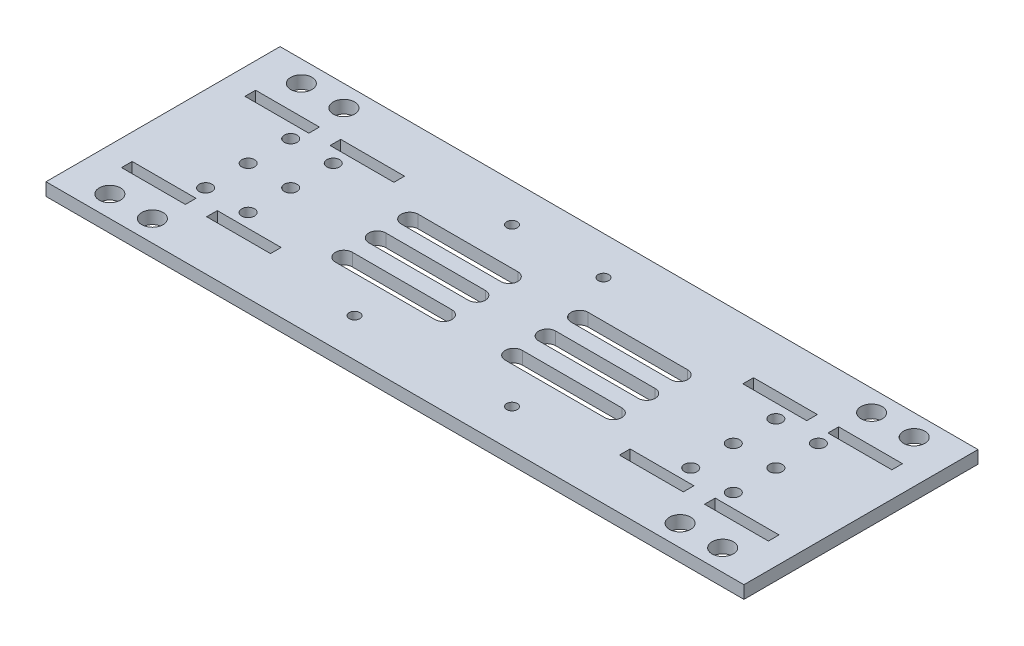
from build123d import *

# Parameters (mm, degrees)
SKETCH1_W           = 164
SKETCH1_H           = 55
SKETCH1_W_2         = 15
SKETCH1_H_2         = 2.5
BOSS_EXTRUDE1_DEPTH = 3
CUT_EXTRUDE1_DEPTH  = 3
SKETCH3_R           = 1.25
CUT_EXTRUDE2_DEPTH  = 10
SKETCH4_R           = 2.5
CUT_EXTRUDE3_DEPTH  = 4
SKETCH5_R           = 1.5
CUT_EXTRUDE4_DEPTH  = 10


with BuildPart() as part:
    # Sketch1 → Boss-Extrude1 (new body)
    with BuildSketch(Plane(origin=(0, 0, 0), x_dir=(1, 0, 0), z_dir=(0, 1, 0))):
        Rectangle(SKETCH1_W, SKETCH1_H)
        with Locations((48.5, 14.5)):
            Rectangle(SKETCH1_W_2, SKETCH1_H_2, mode=Mode.SUBTRACT)
        with Locations((68.5, 14.5)):
            Rectangle(SKETCH1_W_2, SKETCH1_H_2, mode=Mode.SUBTRACT)
        with Locations((68.5, -14.5)):
            Rectangle(SKETCH1_W_2, SKETCH1_H_2, mode=Mode.SUBTRACT)
        with Locations((48.5, -14.5)):
            Rectangle(SKETCH1_W_2, SKETCH1_H_2, mode=Mode.SUBTRACT)
        with Locations((-48.5, -14.5)):
            Rectangle(SKETCH1_W_2, SKETCH1_H_2, mode=Mode.SUBTRACT)
        with Locations((-68.5, -14.5)):
            Rectangle(SKETCH1_W_2, SKETCH1_H_2, mode=Mode.SUBTRACT)
        with Locations((-68.5, 14.5)):
            Rectangle(SKETCH1_W_2, SKETCH1_H_2, mode=Mode.SUBTRACT)
        with Locations((-48.5, 14.5)):
            Rectangle(SKETCH1_W_2, SKETCH1_H_2, mode=Mode.SUBTRACT)
    extrude(amount=BOSS_EXTRUDE1_DEPTH)

    # Sketch2 → Cut-Extrude1 (cut)
    with BuildSketch(Plane(origin=(0, 3, 0), x_dir=(1, 0, 0), z_dir=(0, 1, 0))):
        with BuildLine():
            Line((-31.658505885, 2), (-8.266387648, 2))
            ThreePointArc((-8.266387648, 2), (-6.266387648, 0), (-8.266387648, -2))
            Line((-8.266387648, -2), (-31.658505885, -2))
            ThreePointArc((-31.658505885, -2), (-33.658505885, 0), (-31.658505885, 2))
        make_face()
        with BuildLine():
            Line((31.658505885, -9.856733432), (8.266387648, -9.856733432))
            ThreePointArc((8.266387648, -9.856733432), (6.266387648, -7.856733432), (8.266387648, -5.856733432))
            Line((8.266387648, -5.856733432), (31.658505885, -5.856733432))
            ThreePointArc((31.658505885, -5.856733432), (33.658505885, -7.856733432), (31.658505885, -9.856733432))
        make_face()
        with BuildLine():
            Line((-31.658505885, 9.620758334), (-8.266387648, 9.620758334))
            ThreePointArc((-8.266387648, 9.620758334), (-6.266387648, 7.620758334), (-8.266387648, 5.620758334))
            Line((-8.266387648, 5.620758334), (-31.658505885, 5.620758334))
            ThreePointArc((-31.658505885, 5.620758334), (-33.658505885, 7.620758334), (-31.658505885, 9.620758334))
        make_face()
        with BuildLine():
            Line((31.658505885, 5.620758334), (8.266387648, 5.620758334))
            ThreePointArc((8.266387648, 5.620758334), (6.266387648, 7.620758334), (8.266387648, 9.620758334))
            Line((8.266387648, 9.620758334), (31.658505885, 9.620758334))
            ThreePointArc((31.658505885, 9.620758334), (33.658505885, 7.620758334), (31.658505885, 5.620758334))
        make_face()
        with BuildLine():
            Line((-31.658505885, -5.856733432), (-8.266387648, -5.856733432))
            ThreePointArc((-8.266387648, -5.856733432), (-6.266387648, -7.856733432), (-8.266387648, -9.856733432))
            Line((-8.266387648, -9.856733432), (-31.658505885, -9.856733432))
            ThreePointArc((-31.658505885, -9.856733432), (-33.658505885, -7.856733432), (-31.658505885, -5.856733432))
        make_face()
        with BuildLine():
            Line((31.658505885, -2), (8.266387648, -2))
            ThreePointArc((8.266387648, -2), (6.266387648, 0), (8.266387648, 2))
            Line((8.266387648, 2), (31.658505885, 2))
            ThreePointArc((31.658505885, 2), (33.658505885, 0), (31.658505885, -2))
        make_face()
    extrude(amount=-CUT_EXTRUDE1_DEPTH, mode=Mode.SUBTRACT)

    # Sketch3 → Cut-Extrude2 (cut)
    with BuildSketch(Plane(origin=(0, 3, 0), x_dir=(1, 0, 0), z_dir=(0, 1, 0))):
        with Locations((18.5, -18.5)):
            Circle(SKETCH3_R)
        with Locations((-18.5, -18.5)):
            Circle(SKETCH3_R)
        with Locations((-18.5, 18.5)):
            Circle(SKETCH3_R)
        with Locations((3, 18.5)):
            Circle(SKETCH3_R)
    extrude(amount=-CUT_EXTRUDE2_DEPTH, mode=Mode.SUBTRACT)

    # Sketch4 → Cut-Extrude3 (cut, through all)
    with BuildSketch(Plane(origin=(0, 3, 0), x_dir=(1, 0, 0), z_dir=(0, 1, 0))):
        with Locations((72, -22.5)):
            Circle(SKETCH4_R)
        with Locations((62, -22.5)):
            Circle(SKETCH4_R)
        with Locations((72, 22.5)):
            Circle(SKETCH4_R)
        with Locations((62, 22.5)):
            Circle(SKETCH4_R)
        with Locations((-72, 22.5)):
            Circle(SKETCH4_R)
        with Locations((-62, 22.5)):
            Circle(SKETCH4_R)
        with Locations((-72, -22.5)):
            Circle(SKETCH4_R)
        with Locations((-62, -22.5)):
            Circle(SKETCH4_R)
    extrude(amount=-CUT_EXTRUDE3_DEPTH, mode=Mode.SUBTRACT)

    # Sketch5 → Cut-Extrude4 (cut)
    with BuildSketch(Plane.XZ):
        with Locations((52, 10)):
            Circle(SKETCH5_R)
        with Locations((62, 10)):
            Circle(SKETCH5_R)
        with Locations((62, 0)):
            Circle(SKETCH5_R)
        with Locations((52, 0)):
            Circle(SKETCH5_R)
        with Locations((52, -10)):
            Circle(SKETCH5_R)
        with Locations((62, -10)):
            Circle(SKETCH5_R)
        with Locations((-52, 10)):
            Circle(SKETCH5_R)
        with Locations((-52, 0)):
            Circle(SKETCH5_R)
        with Locations((-52, -10)):
            Circle(SKETCH5_R)
        with Locations((-62, 10)):
            Circle(SKETCH5_R)
        with Locations((-62, 0)):
            Circle(SKETCH5_R)
        with Locations((-62, -10)):
            Circle(SKETCH5_R)
    extrude(amount=-CUT_EXTRUDE4_DEPTH, mode=Mode.SUBTRACT)


solid = part.part
